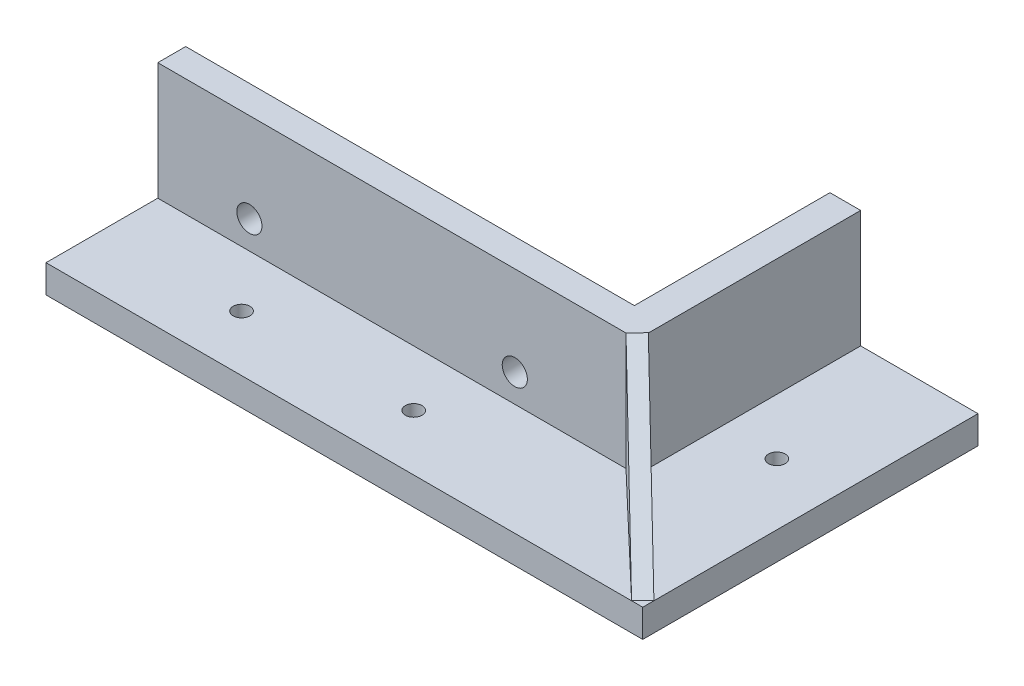
from build123d import *

# Parameters (mm, degrees)
CROQUIS1_W              = 80.8
CROQUIS1_H              = 25
CROQUIS1_R              = 1.5
SALIENTE_EXTRUIR1_DEPTH = 5
CROQUIS1_3_W            = 80.8
CROQUIS1_3_H            = 5
SALIENTE_EXTRUIR2_DEPTH = 26
CROQUIS1_4_W            = 26
CROQUIS1_4_H            = 60
CROQUIS1_4_R            = 1.5
SALIENTE_EXTRUIR3_DEPTH = 5
CROQUIS1_5_W            = 5
CROQUIS1_5_H            = 40
SALIENTE_EXTRUIR4_DEPTH = 26
CROQUIS3_R              = 2.25
CORTAR_EXTRUIR1_DEPTH   = 26
SALIENTE_EXTRUIR5_DEPTH = 21
CORTAR_EXTRUIR2_DEPTH   = 21
CROQUIS6_W              = 37.983880197
CROQUIS6_H              = 26
CORTAR_EXTRUIR3_DEPTH   = 120
CROQUIS7_W              = 35
CROQUIS7_H              = 26
SALIENTE_EXTRUIR6_DEPTH = 0.5


with BuildPart() as part:
    # Croquis1 → Saliente-Extruir1 (new body)
    with BuildSketch(Plane(origin=(0, 0, 0), x_dir=(1, 0, 0), z_dir=(0, 1, 0))):
        with Locations((0, -10)):
            Rectangle(CROQUIS1_W, CROQUIS1_H)
        with Locations((15.4, -12.5)):
            Circle(CROQUIS1_R, mode=Mode.SUBTRACT)
        with Locations((-15.4, -12.5)):
            Circle(CROQUIS1_R, mode=Mode.SUBTRACT)
    extrude(amount=SALIENTE_EXTRUIR1_DEPTH)

    # Croquis1_3 → Saliente-Extruir2 (add)
    with BuildSketch(Plane(origin=(0, 0, 0), x_dir=(1, 0, 0), z_dir=(0, 1, 0))):
        Rectangle(CROQUIS1_3_W, CROQUIS1_3_H)
    extrude(amount=SALIENTE_EXTRUIR2_DEPTH)

    # Croquis1_4 → Saliente-Extruir3 (add)
    # profile 1 of 2: a face of its own
    with BuildSketch(Plane(origin=(0, 0, 0), x_dir=(1, 0, 0), z_dir=(0, 1, 0))):
        with Locations((-53.4, 7.5)):
            Rectangle(CROQUIS1_4_W, CROQUIS1_4_H)
        with Locations((-55.4, 12.5)):
            Circle(CROQUIS1_4_R, mode=Mode.SUBTRACT)
    # profile 2 of 2: a face of its own
    with BuildSketch(Plane(origin=(0, 0, 0), x_dir=(1, 0, 0), z_dir=(0, 1, 0))):
        with Locations((53.4, 7.5)):
            Rectangle(CROQUIS1_4_W, CROQUIS1_4_H)
        with Locations((55.4, 12.5)):
            Circle(CROQUIS1_4_R, mode=Mode.SUBTRACT)
    extrude(amount=SALIENTE_EXTRUIR3_DEPTH)

    # Croquis1_5 → Saliente-Extruir4 (add)
    with BuildSketch(Plane(origin=(0, 0, 0), x_dir=(1, 0, 0), z_dir=(0, 1, 0))):
        with Locations((-42.9, 17.5)):
            Rectangle(CROQUIS1_5_W, CROQUIS1_5_H)
        with Locations((42.9, 17.5)):
            Rectangle(CROQUIS1_5_W, CROQUIS1_5_H)
    extrude(amount=SALIENTE_EXTRUIR4_DEPTH)

    # Croquis3 → Cortar-Extruir1 (cut)
    with BuildSketch(Plane.XY.offset(2.5)):
        with Locations((-24, 10)):
            Circle(CROQUIS3_R)
        with Locations((23.5, 10)):
            Circle(CROQUIS3_R)
    extrude(amount=-CORTAR_EXTRUIR1_DEPTH, mode=Mode.SUBTRACT)

    # Croquis4 → Saliente-Extruir5 (add)
    with BuildSketch(Plane(origin=(0, 5, 0), x_dir=(1, 0, 0), z_dir=(0, 1, 0))):
        Polygon((-45.4, -0.5), (-45.4, -2.5), (-43.4, -2.5), (-64.4, -22.5), (-66.4, -22.5), (-66.4, -20.5), align=None)
    saliente_extruir5 = extrude(amount=SALIENTE_EXTRUIR5_DEPTH)

    # Croquis5 → Cortar-Extruir2 (cut)
    with BuildSketch(Plane(origin=(-19.393579073, 0, -20.363258026), x_dir=(0.7241379310344827, 0, -0.6896551724137933), z_dir=(0.6896551724137933, 0, 0.7241379310344827))):
        Polygon((-62.151724138, 5), (-33.151724138, 26), (-26.486949689, 30.82621598), (-82.759555013, 33.403814281), (-84.060607683, 5), align=None)
    cortar_extruir2 = extrude(amount=-CORTAR_EXTRUIR2_DEPTH, mode=Mode.SUBTRACT)

    # Simetría1: Saliente-Extruir5 across plane
    add(saliente_extruir5.mirror(Plane(origin=(0, 0, 0), x_dir=(0, 0, 1), z_dir=(1, 0, 0))))

    # Simetría2: Cortar-Extruir2 across plane
    add(cortar_extruir2.mirror(Plane(origin=(0, 0, 0), x_dir=(0, 0, 1), z_dir=(1, 0, 0))), mode=Mode.SUBTRACT)

    # Croquis6 → Cortar-Extruir3 (cut)
    with BuildSketch(Plane(origin=(0, 0, -37.5), x_dir=(-1, 0, 0), z_dir=(0, 0, -1))):
        with Locations((59.391940099, 13)):
            Rectangle(CROQUIS6_W, CROQUIS6_H)
    extrude(amount=-CORTAR_EXTRUIR3_DEPTH, mode=Mode.SUBTRACT)

    # Croquis7 → Saliente-Extruir6 (add)
    with BuildSketch(Plane.ZY.offset(-40.4)):
        with Locations((-20, 13)):
            Rectangle(CROQUIS7_W, CROQUIS7_H)
    extrude(amount=SALIENTE_EXTRUIR6_DEPTH)


solid = part.part
